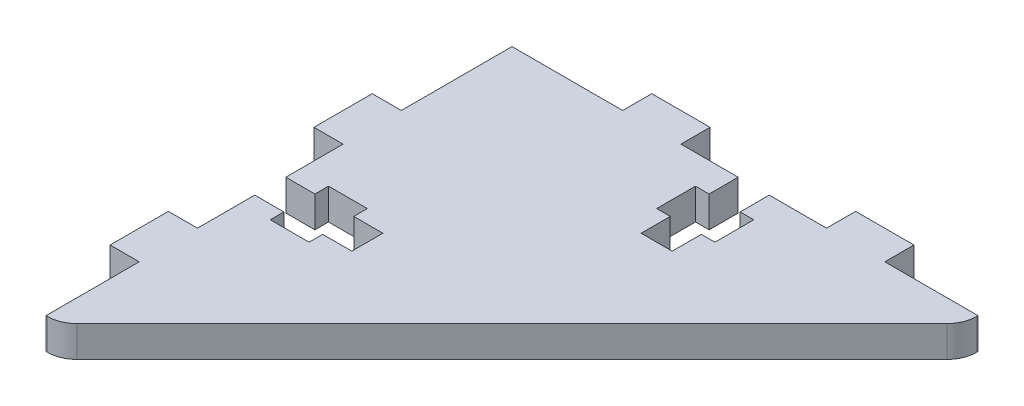
from build123d import *

# Parameters (mm, degrees)
SALIENTE_EXTRUIR2_DEPTH = 3.2


with BuildPart() as part:
    # Croquis1 → Saliente-Extruir2 (new body)
    with BuildSketch(Plane(origin=(0, 0, 0), x_dir=(1, 0, 0), z_dir=(0, 1, 0))):
        with BuildLine():
            Line((10, 21.5), (7, 21.5))
            Line((7, 21.5), (7, 20.1))
            Line((7, 20.1), (3, 20.1))
            Line((3, 20.1), (3, 21.5))
            Line((3, 21.5), (0, 21.5))
            Line((0, 21.5), (0, 15.6))
            Line((0, 15.6), (-3, 15.6))
            Line((-3, 15.6), (-3, 9.6))
            Line((-3, 9.6), (0, 9.6))
            Line((0, 9.6), (0, 0))
            Line((0, 0), (0.171572875, 0))
            ThreePointArc((0.171572875, 0), (1.319623172, 0.228361402), (2.292893219, 0.878679656))
            Line((2.292893219, 0.878679656), (47.121320344, 45.707106781))
            ThreePointArc((47.121320344, 45.707106781), (47.771638598, 46.680376828), (48, 47.828427125))
            Line((48, 47.828427125), (48, 48))
            Line((48, 48), (38.4, 48))
            Line((38.4, 48), (38.4, 51))
            Line((38.4, 51), (32.4, 51))
            Line((32.4, 51), (32.4, 48))
            Line((32.4, 48), (26.5, 48))
            Line((26.5, 48), (26.5, 45))
            Line((26.5, 45), (27.9, 45))
            Line((27.9, 45), (27.9, 41))
            Line((27.9, 41), (26.5, 41))
            Line((26.5, 41), (26.5, 38))
            Line((26.5, 38), (23.3, 38))
            Line((23.3, 38), (23.3, 41))
            Line((23.3, 41), (21.9, 41))
            Line((21.9, 41), (21.9, 45))
            Line((21.9, 45), (23.3, 45))
            Line((23.3, 45), (23.3, 48))
            Line((23.3, 48), (17.4, 48))
            Line((17.4, 48), (17.4, 51))
            Line((17.4, 51), (11.4, 51))
            Line((11.4, 51), (11.4, 48))
            Line((11.4, 48), (0, 48))
            Line((0, 48), (0, 36.6))
            Line((0, 36.6), (-3, 36.6))
            Line((-3, 36.6), (-3, 30.6))
            Line((-3, 30.6), (0, 30.6))
            Line((0, 30.6), (0, 24.7))
            Line((0, 24.7), (3, 24.7))
            Line((3, 24.7), (3, 26.1))
            Line((3, 26.1), (7, 26.1))
            Line((7, 26.1), (7, 24.7))
            Line((7, 24.7), (10, 24.7))
            Line((10, 24.7), (10, 21.5))
        make_face()
    extrude(amount=SALIENTE_EXTRUIR2_DEPTH)


solid = part.part
